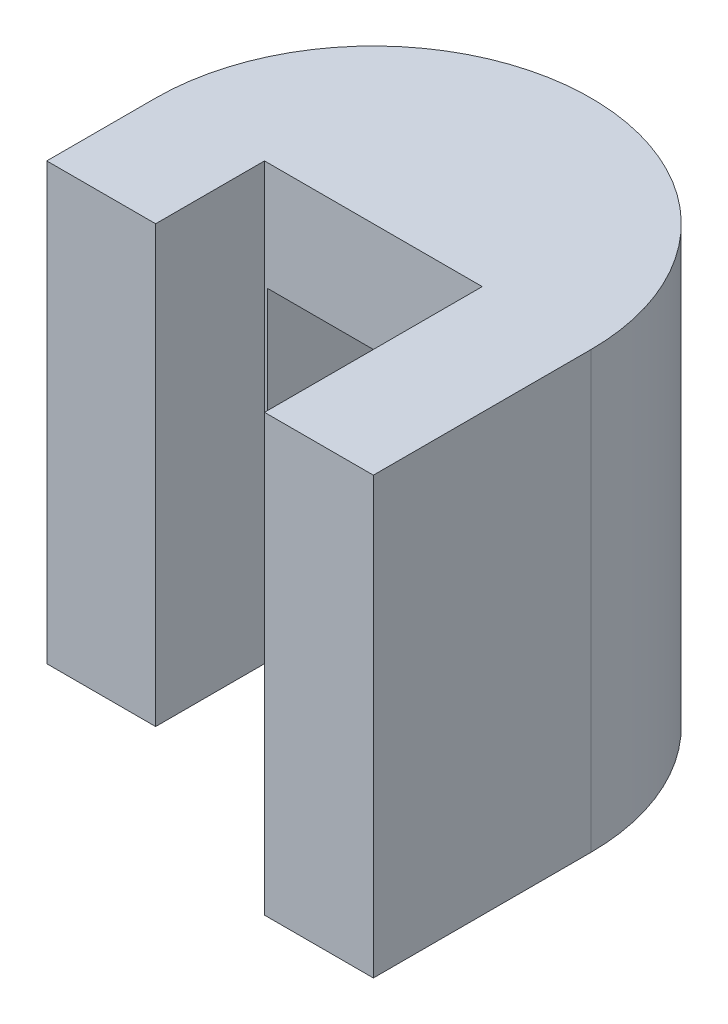
from build123d import *

# Parameters (mm, degrees)
SKETCH1_W           = 40
SKETCH1_H           = 40
BOSS_EXTRUDE1_DEPTH = 40
CUT_EXTRUDE1_DEPTH  = 40
SKETCH3_W           = 2
SKETCH3_H           = 20
CUT_EXTRUDE2_DEPTH  = 40
CUT_EXTRUDE4_DEPTH  = 20
SKETCH9_W           = 18
SKETCH9_H           = 20
CUT_EXTRUDE7_DEPTH  = 1
SKETCH10_W          = 18
SKETCH10_H          = 20
CUT_EXTRUDE8_DEPTH  = 1


with BuildPart() as part:
    # Sketch1 → Boss-Extrude1 (new body)
    with BuildSketch(Plane.XY):
        with Locations((20, 20)):
            Rectangle(SKETCH1_W, SKETCH1_H)
    extrude(amount=BOSS_EXTRUDE1_DEPTH)

    # Sketch2 → Cut-Extrude1 (cut)
    with BuildSketch(Plane(origin=(0, 40, 0), x_dir=(1, 0, 0), z_dir=(0, 1, 0))):
        Polygon((10, -30), (0, -30), (0, -40), (30, -40), (30, -20), (10, -20), align=None)
        with BuildLine():
            Line((40, 0), (20, 0))
            ThreePointArc((20, 0), (34.142135624, -5.857864376), (40, -20))
            Line((40, -20), (40, 0))
        make_face()
        with BuildLine():
            Line((0, 0), (0, -20))
            ThreePointArc((0, -20), (5.857864376, -5.857864376), (20, 0))
            Line((20, 0), (0, 0))
        make_face()
    extrude(amount=-CUT_EXTRUDE1_DEPTH, mode=Mode.SUBTRACT)

    # Sketch3 → Cut-Extrude2 (cut)
    with BuildSketch(Plane(origin=(0, 0, 0), x_dir=(0, 0, -1), z_dir=(1, 0, 0))):
        with Locations((-1, 20)):
            Rectangle(SKETCH3_W, SKETCH3_H)
    extrude(amount=CUT_EXTRUDE2_DEPTH, mode=Mode.SUBTRACT)

    # Sketch5 → Cut-Extrude4 (cut)
    with BuildSketch(Plane(origin=(0, 30, 0), x_dir=(1, 0, 0), z_dir=(0, 1, 0))):
        with BuildLine():
            Line((28.717797887, -2), (28.717797887, -20))
            Line((28.717797887, -20), (11.282202113, -20))
            Line((11.282202113, -20), (11.282202113, -2))
            ThreePointArc((11.282202113, -2), (20, 0), (28.717797887, -2))
        make_face()
    extrude(amount=-CUT_EXTRUDE4_DEPTH, mode=Mode.SUBTRACT)

    # Sketch9 → Cut-Extrude7 (cut)
    with BuildSketch(Plane.ZY.offset(-28.717797887)):
        with Locations((11, 20)):
            Rectangle(SKETCH9_W, SKETCH9_H)
    extrude(amount=-CUT_EXTRUDE7_DEPTH, mode=Mode.SUBTRACT)

    # Sketch10 → Cut-Extrude8 (cut)
    with BuildSketch(Plane(origin=(11.282202113, 0, 0), x_dir=(0, 0, -1), z_dir=(1, 0, 0))):
        with Locations((-11, 20)):
            Rectangle(SKETCH10_W, SKETCH10_H)
    extrude(amount=-CUT_EXTRUDE8_DEPTH, mode=Mode.SUBTRACT)


solid = part.part
